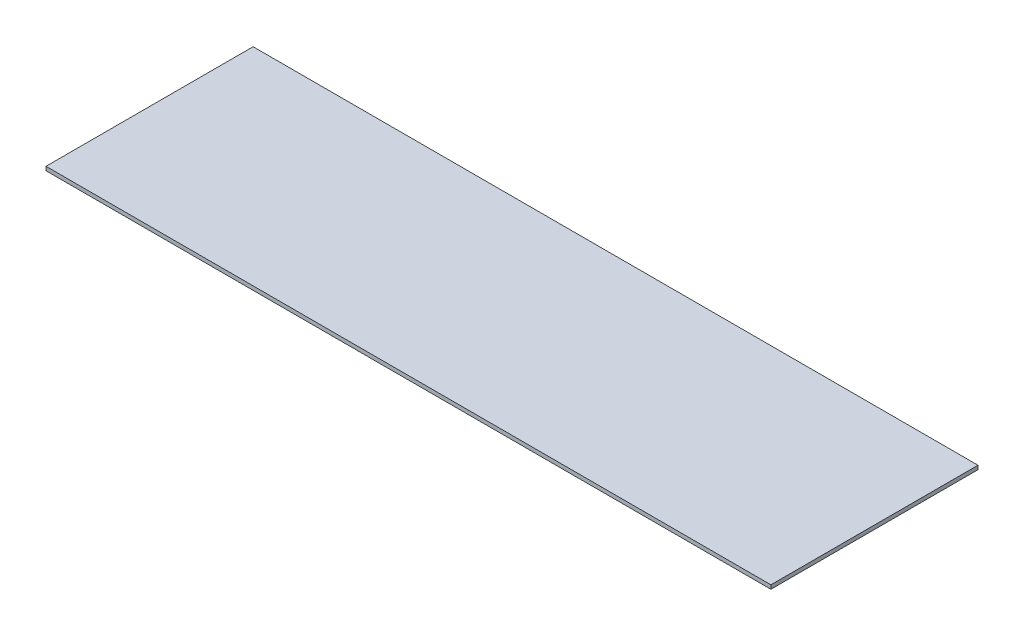
from build123d import *

# Parameters (mm, degrees)
SKETCH1_W           = 28
SKETCH1_H           = 8
BOSS_EXTRUDE1_DEPTH = 0.15


with BuildPart() as part:
    # Sketch1 → Boss-Extrude1 (new body)
    with BuildSketch(Plane(origin=(0, 0, 0), x_dir=(1, 0, 0), z_dir=(0, 1, 0))):
        Rectangle(SKETCH1_W, SKETCH1_H)
    extrude(amount=BOSS_EXTRUDE1_DEPTH)


solid = part.part
